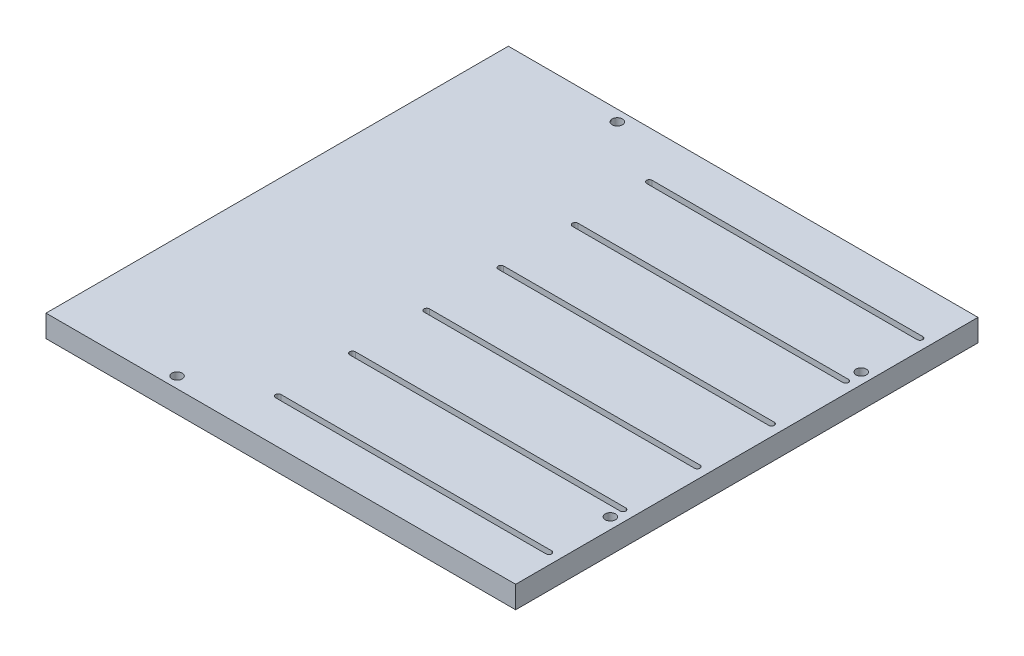
from build123d import *

# Parameters (mm, degrees)
BOSS_EXTRUDE1_DEPTH       = 6.35
F_4_CLEARANCE_HOLE1_D     = 2.9464
CUT_EXTRUDE2_DEPTH        = 7.35
F_4_CLEARANCE_HOLE2_D     = 2.9464
F_4_CLEARANCE_HOLE2_DEPTH = 6.35
F_4_CLEARANCE_HOLE2_TIP   = 0.885187864


with BuildPart() as part:
    # Sketch1 → Boss-Extrude1 (new body)
    with BuildSketch(Plane(origin=(0, 0, 0), x_dir=(1, 0, 0), z_dir=(0, 1, 0))):
        Polygon((-42, -66.35), (42, -66.35), (42, 66.35), (-42, 66.35), (-92.8, 66.35), (-92.8, -66.35), align=None)
    extrude(amount=BOSS_EXTRUDE1_DEPTH)

    # #4 Clearance Hole1 (through all)
    with Locations(Plane(origin=(0, 6.35, 0), x_dir=(1, 0, 0), z_dir=(0, 1, 0))):
        with Locations((38.825, 35.997), (38.825, -35.997)):
            Hole(F_4_CLEARANCE_HOLE1_D / 2)

    # Sketch3 → Cut-Extrude2 (cut, through all)
    with BuildSketch(Plane(origin=(0, 6.35, 0), x_dir=(1, 0, 0), z_dir=(0, 1, 0))):
        with BuildLine():
            Line((-38.825, -52.85625), (38.825, -52.85625))
            ThreePointArc((38.825, -52.85625), (39.61875, -53.65), (38.825, -54.44375))
            Line((38.825, -54.44375), (-38.825, -54.44375))
            ThreePointArc((-38.825, -54.44375), (-39.61875, -53.65), (-38.825, -52.85625))
        make_face()
        with BuildLine():
            Line((-38.825, -31.555), (38.825, -31.555))
            ThreePointArc((38.825, -31.555), (39.61875, -32.34875), (38.825, -33.1425))
            Line((38.825, -33.1425), (-38.825, -33.1425))
            ThreePointArc((-38.825, -33.1425), (-39.61875, -32.34875), (-38.825, -31.555))
        make_face()
        with BuildLine():
            Line((-38.825, -10.25375), (38.825, -10.25375))
            ThreePointArc((38.825, -10.25375), (39.61875, -11.0475), (38.825, -11.84125))
            Line((38.825, -11.84125), (-38.825, -11.84125))
            ThreePointArc((-38.825, -11.84125), (-39.61875, -11.0475), (-38.825, -10.25375))
        make_face()
        with BuildLine():
            Line((-38.825, 11.0475), (38.825, 11.0475))
            ThreePointArc((38.825, 11.0475), (39.61875, 10.25375), (38.825, 9.46))
            Line((38.825, 9.46), (-38.825, 9.46))
            ThreePointArc((-38.825, 9.46), (-39.61875, 10.25375), (-38.825, 11.0475))
        make_face()
        with BuildLine():
            Line((-38.825, 32.34875), (38.825, 32.34875))
            ThreePointArc((38.825, 32.34875), (39.61875, 31.555), (38.825, 30.76125))
            Line((38.825, 30.76125), (-38.825, 30.76125))
            ThreePointArc((-38.825, 30.76125), (-39.61875, 31.555), (-38.825, 32.34875))
        make_face()
        with BuildLine():
            Line((-38.825, 53.65), (38.825, 53.65))
            ThreePointArc((38.825, 53.65), (39.61875, 52.85625), (38.825, 52.0625))
            Line((38.825, 52.0625), (-38.825, 52.0625))
            ThreePointArc((-38.825, 52.0625), (-39.61875, 52.85625), (-38.825, 53.65))
        make_face()
    extrude(amount=-CUT_EXTRUDE2_DEPTH, mode=Mode.SUBTRACT)

    # #4 Clearance Hole2
    with Locations(Plane(origin=(0, 6.35, 0), x_dir=(1, 0, 0), z_dir=(0, 1, 0))):
        with Locations((-58.35, 63.178000009), (-58.35, -63.171999991)):
            Hole(F_4_CLEARANCE_HOLE2_D / 2, depth=F_4_CLEARANCE_HOLE2_DEPTH)
            with Locations((0, 0, -(F_4_CLEARANCE_HOLE2_DEPTH + F_4_CLEARANCE_HOLE2_TIP / 2))):  # 118° drill point
                Cone(0, F_4_CLEARANCE_HOLE2_D / 2, F_4_CLEARANCE_HOLE2_TIP, mode=Mode.SUBTRACT)


solid = part.part
